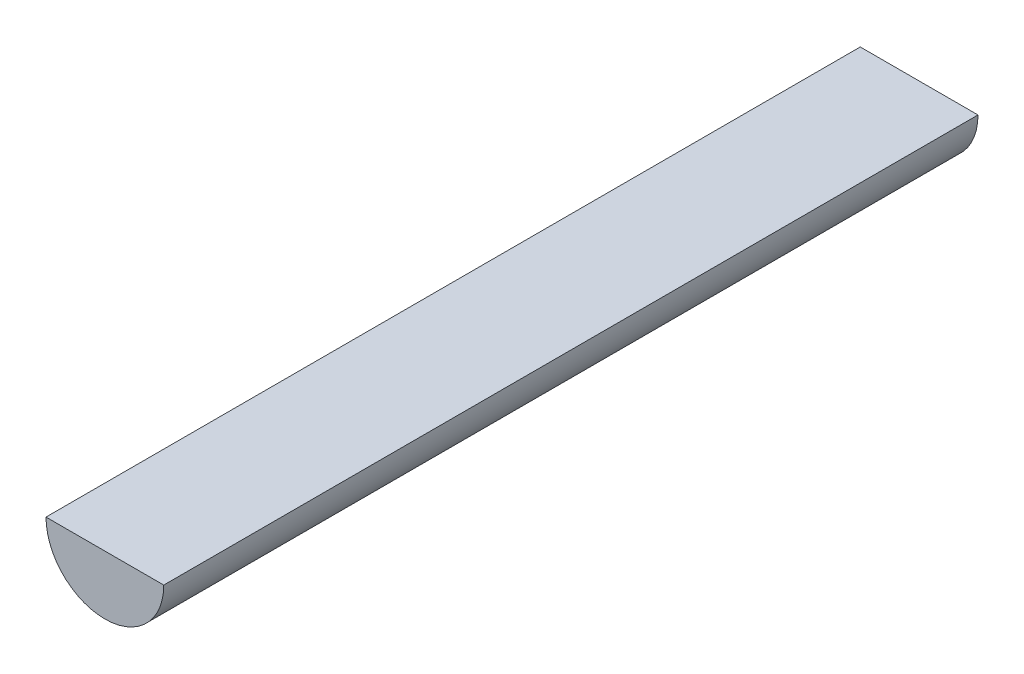
from build123d import *

# Parameters (mm, degrees)
BOSS_EXTRUDE1_DEPTH = 65


with BuildPart() as part:
    # Sketch1 → Boss-Extrude1 (new body)
    with BuildSketch(Plane.XY):
        with BuildLine():
            Line((-4.7, 0), (4.7, 0))
            ThreePointArc((4.7, 0), (0, -4.7), (-4.7, 0))
        make_face()
    extrude(amount=BOSS_EXTRUDE1_DEPTH)


solid = part.part
